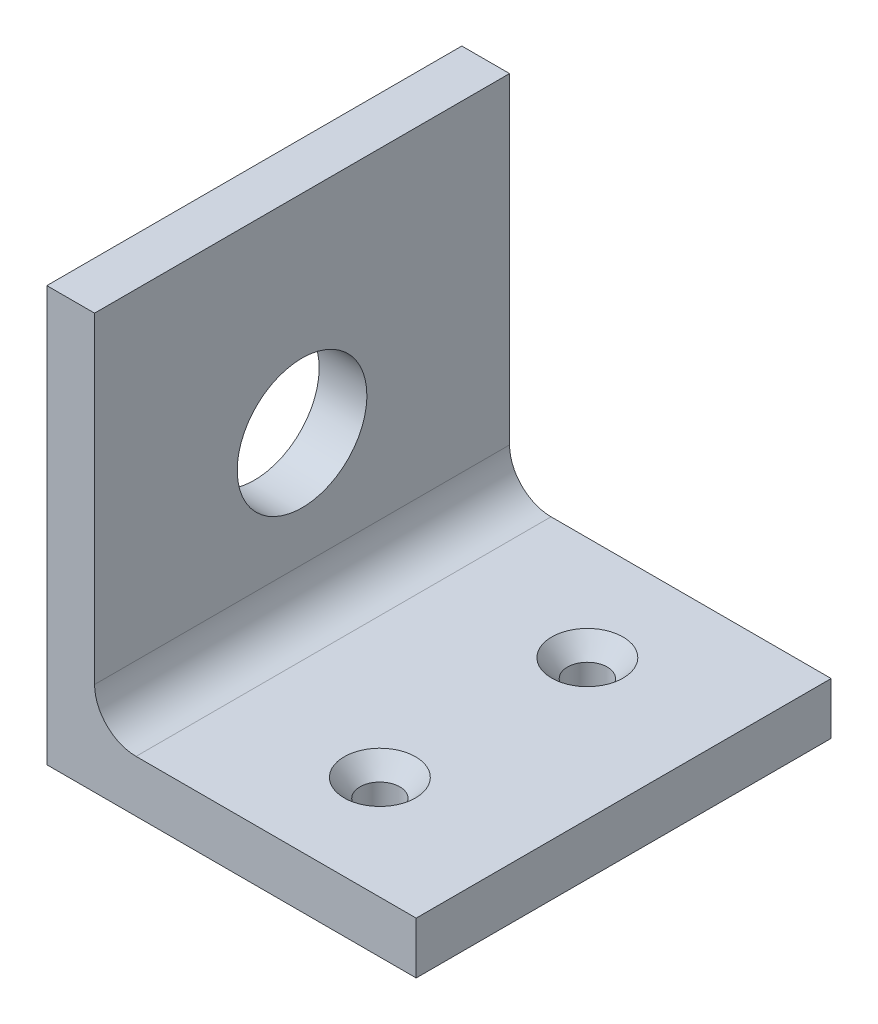
from build123d import *

# Parameters (mm, degrees)
BOSS_EXTRUDE1_DEPTH                            = 25.4
SKETCH5_R                                      = 3.96875
CUT_EXTRUDE2_DEPTH                             = 4.175
CSK_FOR_2_FLAT_HEAD_MACHINE_SCREW1_D           = 2.4384
CSK_FOR_2_FLAT_HEAD_MACHINE_SCREW1_DEPTH       = 3.175
CSK_FOR_2_FLAT_HEAD_MACHINE_SCREW1_CSINK_D     = 4.3688
CSK_FOR_2_FLAT_HEAD_MACHINE_SCREW1_CSINK_ANGLE = 82
SKETCH9_W                                      = 2.54
SKETCH9_H                                      = 25.4
CUT_EXTRUDE3_DEPTH                             = 4.175
FILLET1_R                                      = 2.54
SKETCH10_W                                     = 0.254
SKETCH10_H                                     = 25.4
CUT_EXTRUDE4_DEPTH                             = 26.4


with BuildPart() as part:
    # Sketch1 → Boss-Extrude1 (new body)
    with BuildSketch(Plane.XY):
        Polygon((0, 0), (25.4, 0), (25.4, 3.175), (3.175, 3.175), (3.175, 25.4), (0, 25.4), align=None)
    extrude(amount=BOSS_EXTRUDE1_DEPTH)

    # Sketch5 → Cut-Extrude2 (cut, through all)
    with BuildSketch(Plane(origin=(3.175, 0, 0), x_dir=(0, 0, -1), z_dir=(1, 0, 0))):
        with Locations((-12.7, 12.7)):
            Circle(SKETCH5_R)
    extrude(amount=-CUT_EXTRUDE2_DEPTH, mode=Mode.SUBTRACT)

    # CSK for #2 Flat Head Machine Screw1
    with Locations(Plane(origin=(0, 3.175, 0), x_dir=(1, 0, 0), z_dir=(0, 1, 0))):
        with Locations((14.2875, -19.05), (14.2875, -6.35)):
            CounterSinkHole(CSK_FOR_2_FLAT_HEAD_MACHINE_SCREW1_D / 2, CSK_FOR_2_FLAT_HEAD_MACHINE_SCREW1_CSINK_D / 2, depth=CSK_FOR_2_FLAT_HEAD_MACHINE_SCREW1_DEPTH, counter_sink_angle=CSK_FOR_2_FLAT_HEAD_MACHINE_SCREW1_CSINK_ANGLE)

    # Sketch9 → Cut-Extrude3 (cut, through all)
    with BuildSketch(Plane(origin=(0, 3.175, 0), x_dir=(1, 0, 0), z_dir=(0, 1, 0))):
        with Locations((24.13, -12.7)):
            Rectangle(SKETCH9_W, SKETCH9_H)
    extrude(amount=-CUT_EXTRUDE3_DEPTH, mode=Mode.SUBTRACT)

    # Fillet1
    fillet1_edges = [part.edges().sort_by_distance(p)[0] for p in [
        (3.175, 3.175, 12.7),
    ]]
    fillet(fillet1_edges, radius=FILLET1_R)

    # Sketch10 → Cut-Extrude4 (cut, through all)
    with BuildSketch(Plane(origin=(0, 25.4, 0), x_dir=(1, 0, 0), z_dir=(0, 1, 0))):
        with Locations((0.127, -12.7)):
            Rectangle(SKETCH10_W, SKETCH10_H)
    extrude(amount=-CUT_EXTRUDE4_DEPTH, mode=Mode.SUBTRACT)


solid = part.part
